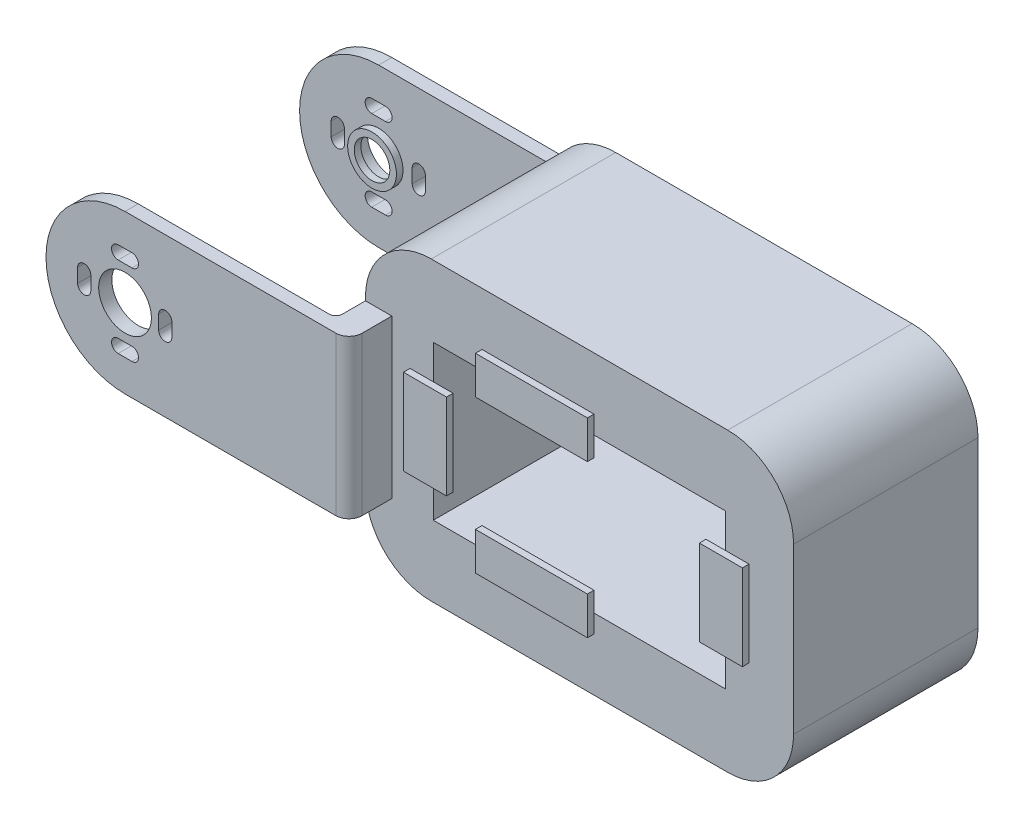
from build123d import *

# Parameters (mm, degrees)
SKETCH_1_W             = 65
SKETCH_1_H             = 45
EXTRUDE_1_DEPTH        = 28
SKETCH_2_W             = 44.4
SKETCH_2_H             = 23.4
CUT_EXTRUDE_1_DEPTH    = 39
SKETCH_3_W             = 4
SKETCH_3_H             = 24
EXTRUDE_2_DEPTH        = 6
EXTRUDE_START          = -0.5
SKETCH_7_R             = 4
EXTRUDE_3_DEPTH        = 2
SKETCH_8_W             = 4
SKETCH_8_H             = 24
EXTRUDE_4_DEPTH        = 6
FILLET_1_R             = 10
FILLET_2_R             = 10
FILLET_3_R             = 10
FILLET_4_R             = 10
PATTERN_LINEAR_2_COUNT = 2
PATTERN_LINEAR_2_PITCH = 38.5
FILLET_5_R             = 2
SKETCH_9_R             = 3.7
SKETCH_9_R_2           = 2.7
EXTRUDE_5_DEPTH        = 1
EXTRUDE_6_DEPTH        = 1
EXTRUDE_6_2_DEPTH      = 1
EXTRUDE_6_3_DEPTH      = 1
SKETCH_10_W            = 17
SKETCH_10_H            = 5.754584259
EXTRUDE_6_4_DEPTH      = 1
SKETCH_12_R            = 4
SKETCH_12_R_2          = 3.7
EXTRUDE_8_DEPTH        = 2
SKETCH_15_W            = 4
SKETCH_15_H            = 24
EXTRUDE_10_DEPTH       = 0.5
FILLET_16_R            = 2
FILLET_17_R            = 1
FILLET_18_R            = 1


with BuildPart() as part:
    # 草圖1 → 填料-伸長1 (new body)
    with BuildSketch(Plane.XY):
        with Locations((-27.434655272, 0)):
            Rectangle(SKETCH_1_W, SKETCH_1_H)
    extrude(amount=EXTRUDE_1_DEPTH)

    # 草圖2 → 除料-伸長1 (cut)
    with BuildSketch(Plane.XY):
        with Locations((-27.434655272, 0)):
            Rectangle(SKETCH_2_W, SKETCH_2_H)
    extrude(amount=CUT_EXTRUDE_1_DEPTH, mode=Mode.SUBTRACT)

    # 草圖3 → 填料-伸長2 (add)
    with BuildSketch(Plane.XY.offset(28)):
        with Locations((-57.934655272, 0)):
            Rectangle(SKETCH_3_W, SKETCH_3_H)
    extrude(amount=EXTRUDE_2_DEPTH)

    # 草圖7 → 填料-伸長3 (add)
    with BuildSketch(Plane.XY.offset(33).offset(EXTRUDE_START)):
        with BuildLine():
            Line((-59.934655272, 12), (-59.934655272, -12))
            Line((-59.934655272, -12), (-89.934655272, -12))
            ThreePointArc((-89.934655272, -12), (-101.934655272, 0), (-89.934655272, 12))
            Line((-89.934655272, 12), (-59.934655272, 12))
        make_face()
        with Locations((-89.934655272, 0)):
            Circle(SKETCH_7_R, mode=Mode.SUBTRACT)
        with BuildLine():
            Line((-95.134655272, 1.05), (-95.134655272, -1.05))
            ThreePointArc((-95.134655272, -1.05), (-96.134655272, -2.05), (-97.134655272, -1.05))
            Line((-97.134655272, -1.05), (-97.134655272, 1.05))
            ThreePointArc((-97.134655272, 1.05), (-96.134655272, 2.05), (-95.134655272, 1.05))
        make_face(mode=Mode.SUBTRACT)
        with BuildLine():
            Line((-90.984655272, -5.2), (-88.884655272, -5.2))
            ThreePointArc((-88.884655272, -5.2), (-87.884655272, -6.2), (-88.884655272, -7.2))
            Line((-88.884655272, -7.2), (-90.984655272, -7.2))
            ThreePointArc((-90.984655272, -7.2), (-91.984655272, -6.2), (-90.984655272, -5.2))
        make_face(mode=Mode.SUBTRACT)
        with BuildLine():
            Line((-90.984655272, 5.1), (-88.884655272, 5.1))
            ThreePointArc((-88.884655272, 5.1), (-87.884655272, 6.1), (-88.884655272, 7.1))
            Line((-88.884655272, 7.1), (-90.984655272, 7.1))
            ThreePointArc((-90.984655272, 7.1), (-91.984655272, 6.1), (-90.984655272, 5.1))
        make_face(mode=Mode.SUBTRACT)
        with BuildLine():
            Line((-84.834655272, 1.05), (-84.834655272, -1.05))
            ThreePointArc((-84.834655272, -1.05), (-83.834655272, -2.05), (-82.834655272, -1.05))
            Line((-82.834655272, -1.05), (-82.834655272, 1.05))
            ThreePointArc((-82.834655272, 1.05), (-83.834655272, 2.05), (-84.834655272, 1.05))
        make_face(mode=Mode.SUBTRACT)
    extrude_3 = extrude(amount=EXTRUDE_3_DEPTH)

    # 草圖8 → 填料-伸長4 (add)
    with BuildSketch(Plane(origin=(0, 0, 0), x_dir=(-1, 0, 0), z_dir=(0, 0, -1))):
        with Locations((57.934655272, 0)):
            Rectangle(SKETCH_8_W, SKETCH_8_H)
    extrude(amount=EXTRUDE_4_DEPTH)

    # 圓角1
    fillet_1_edges = [part.edges().sort_by_distance(p)[0] for p in [
        (-59.934655272, -22.5, 14),
    ]]
    fillet(fillet_1_edges, radius=FILLET_1_R)

    # 圓角2
    fillet_2_edges = [part.edges().sort_by_distance(p)[0] for p in [
        (-59.934655272, 22.5, 14),
    ]]
    fillet(fillet_2_edges, radius=FILLET_2_R)

    # 圓角3
    fillet_3_edges = [part.edges().sort_by_distance(p)[0] for p in [
        (5.065344728, 22.5, 14),
    ]]
    fillet(fillet_3_edges, radius=FILLET_3_R)

    # 圓角4
    fillet_4_edges = [part.edges().sort_by_distance(p)[0] for p in [
        (5.065344728, -22.5, 14),
    ]]
    fillet(fillet_4_edges, radius=FILLET_4_R)

    # 直線複製排列2: 填料-伸長3 ×2
    with Locations(*[(0, 0, -i * PATTERN_LINEAR_2_PITCH) for i in range(1, PATTERN_LINEAR_2_COUNT)]):
        add(extrude_3)

    # 圓角5
    fillet_5_edges = [part.edges().sort_by_distance(p)[0] for p in [
        (-55.934655272, 0, -6),
    ]]
    fillet(fillet_5_edges, radius=FILLET_5_R)

    # 草圖12 → 填料-伸長8 (add)
    with BuildSketch(Plane(origin=(0, 0, -4), x_dir=(-1, 0, 0), z_dir=(0, 0, -1))):
        with Locations((89.934655272, 0)):
            Circle(SKETCH_12_R)
        with Locations((89.934655272, 0)):
            Circle(SKETCH_12_R_2, mode=Mode.SUBTRACT)
    extrude(amount=EXTRUDE_8_DEPTH)

    # 草圖15 → 填料-伸長10 (add)
    with BuildSketch(Plane.XY.offset(34)):
        with Locations((-57.934655272, 0)):
            Rectangle(SKETCH_15_W, SKETCH_15_H)
    extrude(amount=EXTRUDE_10_DEPTH)

    # 圓角16
    fillet_16_edges = [part.edges().sort_by_distance(p)[0] for p in [
        (-55.934655272, 0, 34.5),
    ]]
    fillet(fillet_16_edges, radius=FILLET_16_R)

    # 圓角17
    fillet_17_edges = [part.edges().sort_by_distance(p)[0] for p in [
        (-59.934655272, 0, 32.5),
    ]]
    fillet(fillet_17_edges, radius=FILLET_17_R)

    # 圓角18
    fillet_18_edges = [part.edges().sort_by_distance(p)[0] for p in [
        (-59.934655272, 0, -4),
    ]]
    fillet(fillet_18_edges, radius=FILLET_18_R)


with BuildPart() as body_2:
    # 草圖9 → 填料-伸長5 (new body)
    with BuildSketch(Plane.XY.offset(-4)):
        with Locations((-89.934655272, 0)):
            Circle(SKETCH_9_R)
        with Locations((-89.934655272, 0)):
            Circle(SKETCH_9_R_2, mode=Mode.SUBTRACT)
    extrude(amount=EXTRUDE_5_DEPTH)


with BuildPart() as body_3:
    # 草圖10 → 填料-伸長6 (new body)
    with BuildSketch(Plane.XY.offset(29)):
        Polygon((-49.634655272, 6.5), (-53.165057103, 6.5), (-53.165057103, -6.5), (-46.634655272, -6.5), (-46.634655272, 6.5), align=None)
    extrude(amount=-EXTRUDE_6_DEPTH)


with BuildPart() as body_4:
    # 草圖10 → Extrude 6 2 (new body)
    with BuildSketch(Plane.XY.offset(29)):
        Polygon((-42.234655272, -11.7), (-42.234655272, -8.7), (-25.234655272, -8.7), (-25.234655272, -14.454584259), (-42.234655272, -14.454584259), align=None)
    extrude(amount=-EXTRUDE_6_2_DEPTH)


with BuildPart() as body_5:
    # 草圖10 → Extrude 6 3 (new body)
    with BuildSketch(Plane.XY.offset(29)):
        Polygon((-8.234655272, 6.5), (-8.234655272, -6.5), (-5.234655272, -6.5), (-1.70425344, -6.5), (-1.70425344, 6.5), align=None)
    extrude(amount=-EXTRUDE_6_3_DEPTH)


with BuildPart() as body_6:
    # 草圖10 → Extrude 6 4 (new body)
    with BuildSketch(Plane.XY.offset(29)):
        with Locations((-33.734655272, 11.57729213)):
            Rectangle(SKETCH_10_W, SKETCH_10_H)
    extrude(amount=-EXTRUDE_6_4_DEPTH)


solid = Compound([part.part, body_2.part, body_3.part, body_4.part, body_5.part, body_6.part])
